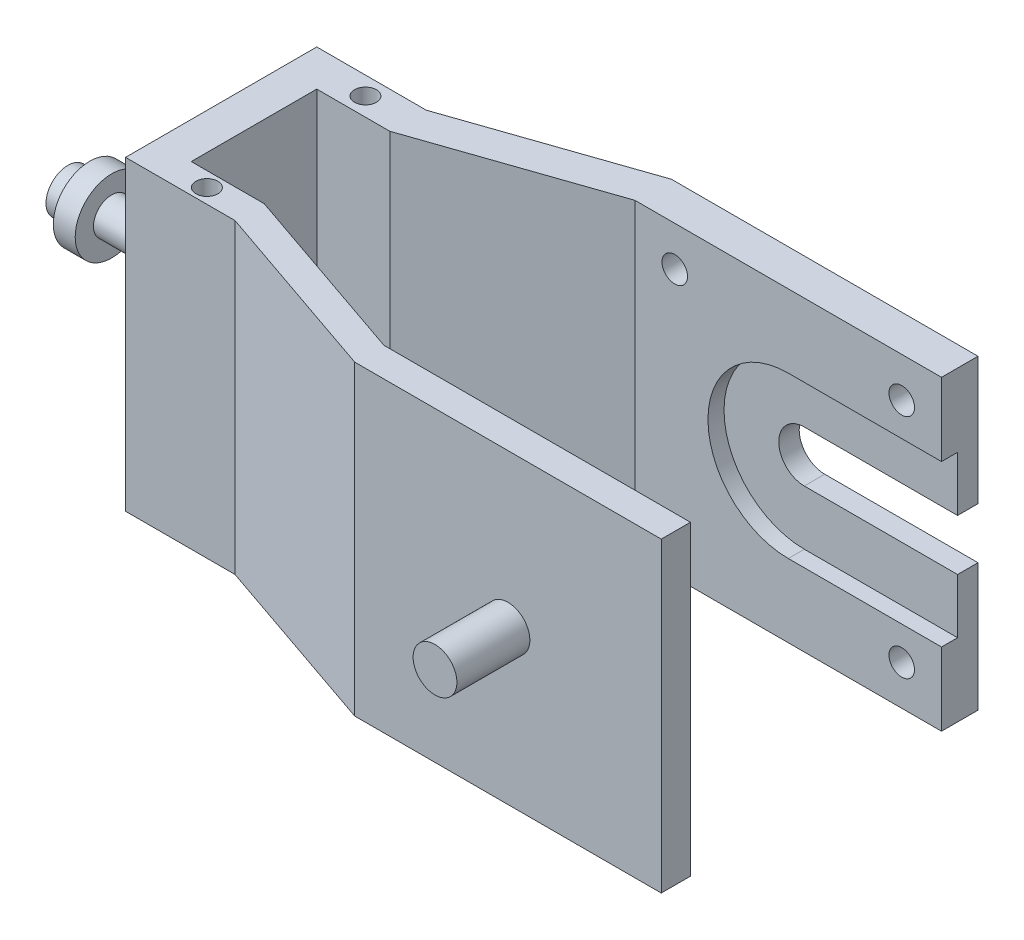
from build123d import *

# Parameters (mm, degrees)
BOSS_EXTRUDE1_DEPTH = 42
CUT_EXTRUDE2_DEPTH  = 2.2
CUT_EXTRUDE3_DEPTH  = 5
SKETCH7_R           = 1.75
CUT_EXTRUDE5_DEPTH  = 5
SKETCH8_R           = 2.5
BOSS_EXTRUDE2_DEPTH = 15
SKETCH9_R           = 3
BOSS_EXTRUDE3_DEPTH = 14
SKETCH10_R          = 1.5
CUT_EXTRUDE6_DEPTH  = 10
SKETCH11_R          = 5
BOSS_EXTRUDE4_DEPTH = 3
SKETCH12_R          = 3
BOSS_EXTRUDE5_DEPTH = 3


with BuildPart() as part:
    # Sketch1 → Boss-Extrude1 (new body)
    with BuildSketch(Plane(origin=(0, 0, 0), x_dir=(1, 0, 0), z_dir=(0, 1, 0))):
        Polygon((0, 17.2), (-42, 17.2), (-67, 8.6), (-77, 8.6), (-77, -8.6), (-67, -8.6), (-42, -17.2), (0, -17.2), (0, -21.2), (-42, -21.2), (-67, -12.6), (-82, -12.6), (-82, 13.6), (-67, 13.6), (-42, 22.2), (0, 22.2), align=None)
    extrude(amount=BOSS_EXTRUDE1_DEPTH)

    # Sketch3 → Cut-Extrude2 (cut)
    with BuildSketch(Plane.XY.offset(-17.2)):
        with BuildLine():
            Line((-21, 32), (0, 32))
            Line((0, 32), (0, 10))
            Line((0, 10), (-21, 10))
            ThreePointArc((-21, 10), (-32, 21), (-21, 32))
        make_face()
    extrude(amount=-CUT_EXTRUDE2_DEPTH, mode=Mode.SUBTRACT)

    # Sketch4 → Cut-Extrude3 (cut)
    with BuildSketch(Plane.XY.offset(-17.2)):
        with BuildLine():
            Line((-21, 24.5), (0, 24.5))
            Line((0, 24.5), (0, 17.5))
            Line((0, 17.5), (-21, 17.5))
            ThreePointArc((-21, 17.5), (-24.5, 21), (-21, 24.5))
        make_face()
    extrude(amount=-CUT_EXTRUDE3_DEPTH, mode=Mode.SUBTRACT)

    # Sketch7 → Cut-Extrude5 (cut)
    with BuildSketch(Plane(origin=(0, 0, -22.2), x_dir=(-1, 0, 0), z_dir=(0, 0, -1))):
        with Locations((5.45, 36.55)):
            Circle(SKETCH7_R)
        with Locations((36.55, 36.55)):
            Circle(SKETCH7_R)
        with Locations((5.45, 5.45)):
            Circle(SKETCH7_R)
        with Locations((36.55, 5.45)):
            Circle(SKETCH7_R)
    extrude(amount=-CUT_EXTRUDE5_DEPTH, mode=Mode.SUBTRACT)

    # Sketch8 → Boss-Extrude2 (add)
    with BuildSketch(Plane.ZY.offset(82)):
        with Locations((-0.5, 21)):
            Circle(SKETCH8_R)
    extrude(amount=BOSS_EXTRUDE2_DEPTH)

    # Sketch9 → Boss-Extrude3 (add)
    with BuildSketch(Plane(origin=(0, 0, 17.2), x_dir=(-1, 0, 0), z_dir=(0, 0, -1))):
        with Locations((21, 21)):
            Circle(SKETCH9_R)
    extrude(amount=-BOSS_EXTRUDE3_DEPTH)

    # Sketch10 → Cut-Extrude6 (cut)
    with BuildSketch(Plane(origin=(0, 42, 0), x_dir=(1, 0, 0), z_dir=(0, 1, 0))):
        with Locations((-72.845749412, 11.114300727)):
            Circle(SKETCH10_R)
        with Locations((-72.845749412, -10.607252687)):
            Circle(SKETCH10_R)
    extrude(amount=-CUT_EXTRUDE6_DEPTH, mode=Mode.SUBTRACT)

    # Sketch11 → Boss-Extrude4 (add)
    with BuildSketch(Plane.ZY.offset(97)):
        with Locations((-0.5, 21)):
            Circle(SKETCH11_R)
    extrude(amount=BOSS_EXTRUDE4_DEPTH)

    # Sketch12 → Boss-Extrude5 (add)
    with BuildSketch(Plane.ZY.offset(100)):
        with Locations((-0.5, 21)):
            Circle(SKETCH12_R)
    extrude(amount=BOSS_EXTRUDE5_DEPTH)


solid = part.part
